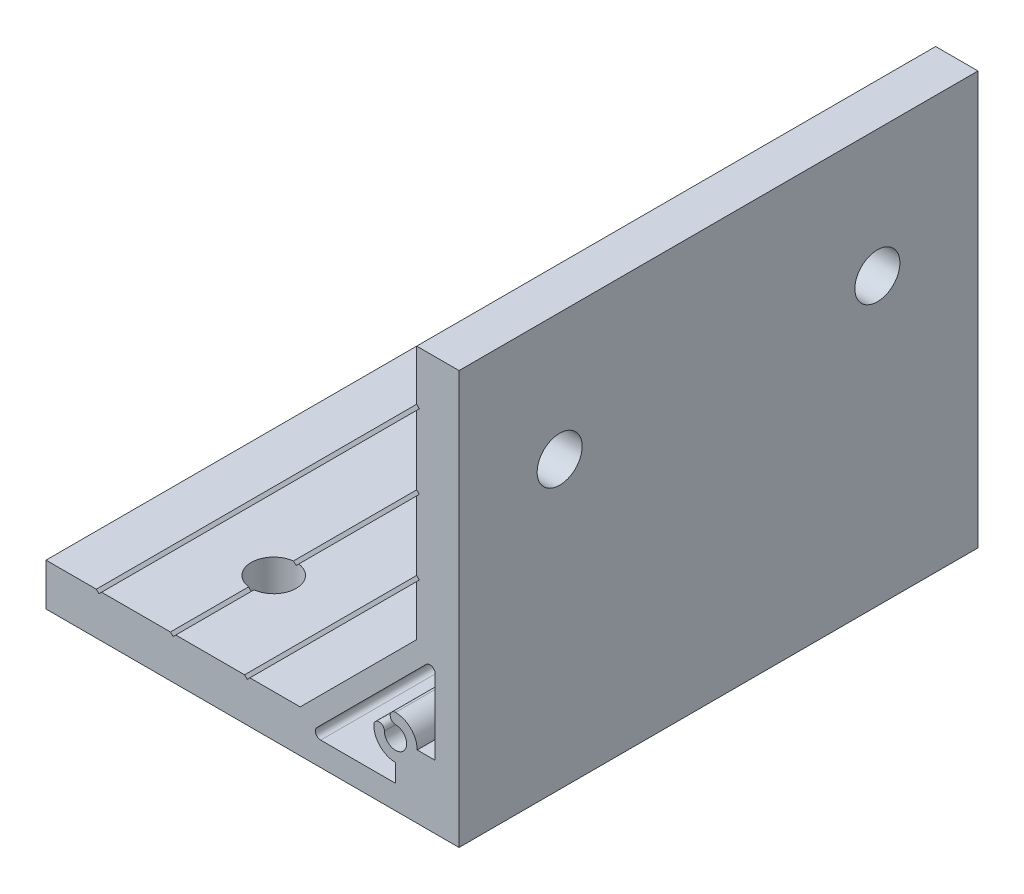
from build123d import *

# Parameters (mm, degrees)
EXTRUDE_1_DEPTH     = 49
SKETCH_2_R          = 4.25
CUT_EXTRUDE_1_DEPTH = 9
SKETCH_3_R          = 4.25
CUT_EXTRUDE_2_DEPTH = 9


with BuildPart() as part:
    # Эскиз1 → Бобышка-Вытянуть1 (new body, symmetric)
    with BuildSketch(Plane.XY):
        Polygon((-78, 0), (0, 0), (0, 78), (-8, 78), (-8, 68.5), (-7.5, 68), (-8, 67.5), (-8, 54.5), (-7.5, 54), (-8, 53.5), (-8, 40.5), (-7.5, 40), (-8, 39.5), (-8, 30), (-30, 8), (-39.5, 8), (-40, 7.5), (-40.5, 8), (-53.5, 8), (-54, 7.5), (-54.5, 8), (-67.5, 8), (-68, 7.5), (-68.5, 8), (-78, 8), align=None)
        with BuildLine():
            Line((-4.5, 12), (-4.5, 26.136038969))
            ThreePointArc((-4.5, 26.136038969), (-5.117316568, 27.059918502), (-6.207106781, 26.843145751))
            Line((-6.207106781, 26.843145751), (-26.843145751, 6.207106781))
            ThreePointArc((-26.843145751, 6.207106781), (-27.059918502, 5.117316568), (-26.136038969, 4.5))
            Line((-26.136038969, 4.5), (-12, 4.5))
            Line((-12, 4.5), (-12, 7.9))
            ThreePointArc((-12, 7.9), (-14.899137803, 9.100862197), (-16.1, 12))
            ThreePointArc((-16.1, 12), (-15.1, 13), (-14.1, 12))
            ThreePointArc((-14.1, 12), (-10.51507576, 10.51507576), (-12, 14.1))
            ThreePointArc((-12, 14.1), (-13, 15.1), (-12, 16.1))
            ThreePointArc((-12, 16.1), (-9.100862197, 14.899137803), (-7.9, 12))
            Line((-7.9, 12), (-4.5, 12))
        make_face(mode=Mode.SUBTRACT)
    extrude(amount=EXTRUDE_1_DEPTH, both=True)

    # Эскиз2 → Вырез-Вытянуть1 (cut, through all)
    with BuildSketch(Plane.ZY.offset(8)):
        with Locations(Location((-30, 54, 0), (0, 0, 270))):  # turned: the seam where the file's is
            Circle(SKETCH_2_R)
        with Locations(Location((30, 54, 0), (0, 0, 270))):  # turned: the seam where the file's is
            Circle(SKETCH_2_R)
    extrude(amount=-CUT_EXTRUDE_1_DEPTH, mode=Mode.SUBTRACT)

    # Эскиз3 → Вырез-Вытянуть2 (cut, through all)
    with BuildSketch(Plane(origin=(0, 8, 0), x_dir=(1, 0, 0), z_dir=(0, 1, 0))):
        with Locations(Location((-54, -30, 0), (0, 0, 180))):  # turned: the seam where the file's is
            Circle(SKETCH_3_R)
        with Locations(Location((-54, 30, 0), (0, 0, 180))):  # turned: the seam where the file's is
            Circle(SKETCH_3_R)
    extrude(amount=-CUT_EXTRUDE_2_DEPTH, mode=Mode.SUBTRACT)


solid = part.part
